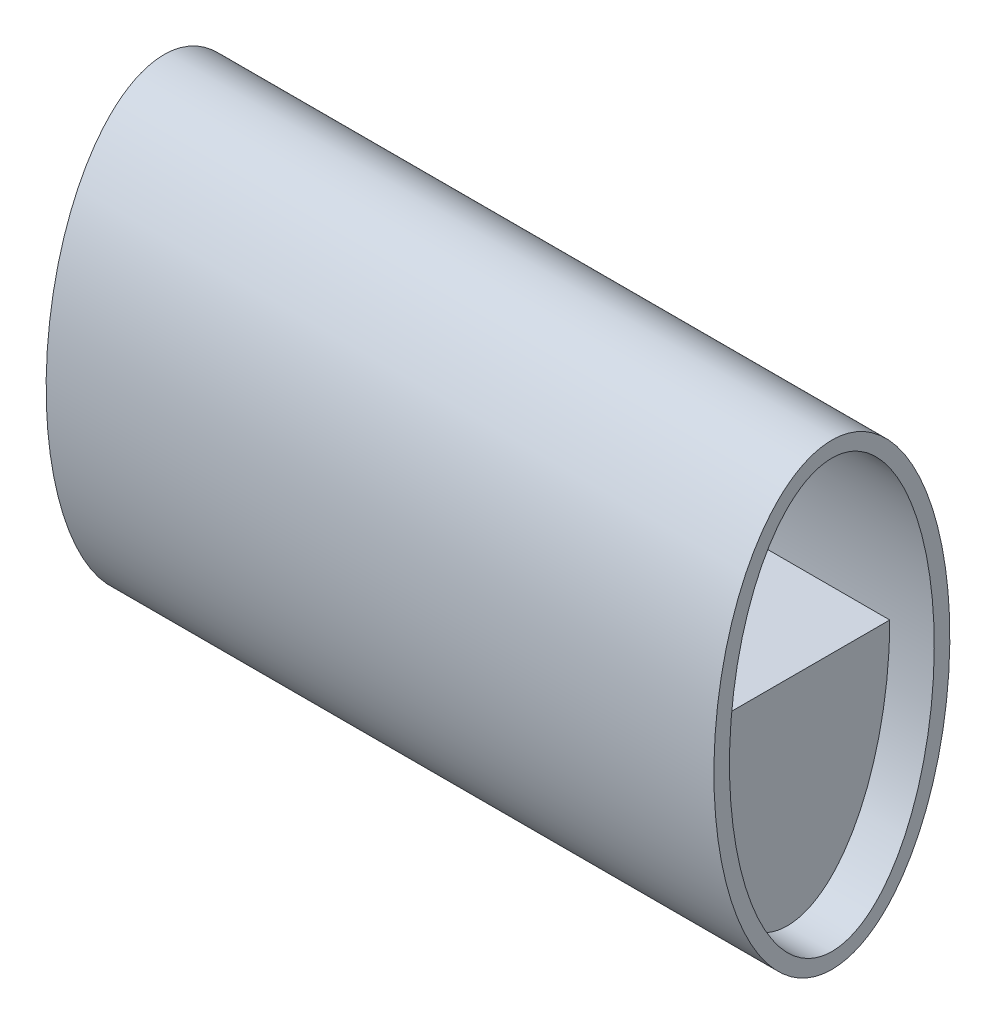
from build123d import *

# Parameters (mm, degrees)
SKETCH_1_RX              = 103
SKETCH_1_RY              = 53
SKETCH_1_RX_2            = 96
SKETCH_1_RY_2            = 46
EXTRUDE_1_DEPTH          = 300
SKETCH_2_RX              = 96
SKETCH_2_RY              = 46
EXTRUDE_2_DEPTH          = 30
EXTRUDE_2_DEPTH_BACK     = 30
SKETCH_3_RX              = 96
SKETCH_3_RY              = 46
CUT_EXTRUDE_1_DEPTH      = 27
CUT_EXTRUDE_1_DEPTH_BACK = 27
EXTRUDE_3_DEPTH          = 100
EXTRUDE_4_DEPTH          = 100
EXTRUDE_5_REACH          = 179


with BuildPart() as part:
    # Эскиз1 → Бобышка-Вытянуть1 (new body)
    with BuildSketch(Plane(origin=(0, 0, 0), x_dir=(0, 0, -1), z_dir=(1, 0, 0))):
        with Locations(Location((0, 0), (0, 0, -90))):
            Ellipse(SKETCH_1_RX, SKETCH_1_RY)
        with Locations(Location((0, 0), (0, 0, -90))):
            Ellipse(SKETCH_1_RX_2, SKETCH_1_RY_2, mode=Mode.SUBTRACT)
    extrude(amount=EXTRUDE_1_DEPTH)

    # Эскиз2 → Бобышка-Вытянуть2 (add, two sides)
    with BuildSketch(Plane.ZY.offset(-150)) as extrude_2_sk:
        with Locations(Location((0, 0), (0, 0, -90))):
            Ellipse(SKETCH_2_RX, SKETCH_2_RY)
    extrude(amount=EXTRUDE_2_DEPTH)
    extrude(extrude_2_sk.sketch, amount=-EXTRUDE_2_DEPTH_BACK)

    # Эскиз3 → Вырез-Вытянуть1 (cut, two sides)
    with BuildSketch(Plane.ZY.offset(-150)) as cut_extrude_1_sk:
        with Locations(Location((0, 0), (0, 0, 90))):
            Ellipse(SKETCH_3_RX, SKETCH_3_RY)
    extrude(amount=CUT_EXTRUDE_1_DEPTH, mode=Mode.SUBTRACT)
    extrude(cut_extrude_1_sk.sketch, amount=-CUT_EXTRUDE_1_DEPTH_BACK, mode=Mode.SUBTRACT)

    # Эскиз4 → Бобышка-Вытянуть3 (add)
    with BuildSketch(Plane.ZY.offset(-120)):
        with BuildLine():
            Line((-46, 0), (46, 0))
            add(Edge.make_bspline(
                [(-46, 0), (-46, -96), (0, -96), (46, -96), (46, 0)],
                knots=[4.71238898, 4.71238898, 4.71238898, 6.283185307, 6.283185307, 7.853981634, 7.853981634, 7.853981634], degree=2, weights=[1, 0.707106781, 1, 0.707106781, 1]))
        make_face()
    extrude(amount=EXTRUDE_3_DEPTH)

    # Эскиз5 → Бобышка-Вытянуть4 (add)
    with BuildSketch(Plane(origin=(180, 0, 0), x_dir=(0, 0, -1), z_dir=(1, 0, 0))):
        with BuildLine():
            Line((-46, 0), (46, 0))
            add(Edge.make_bspline(
                [(-46, 0), (-46, -96), (0, -96), (46, -96), (46, 0)],
                knots=[4.71238898, 4.71238898, 4.71238898, 6.283185307, 6.283185307, 7.853981634, 7.853981634, 7.853981634], degree=2, weights=[1, 0.707106781, 1, 0.707106781, 1]))
        make_face()
    extrude(amount=EXTRUDE_4_DEPTH)

    # Эскиз6 → Бобышка-Вытянуть5 (add, up to next)
    with BuildSketch(Plane(origin=(123, 0, 0), x_dir=(0, 0, -1), z_dir=(1, 0, 0)), mode=Mode.PRIVATE) as extrude_5_sk1:
        with BuildLine():
            Line((-46, 0), (46, 0))
            add(Edge.make_bspline(
                [(-46, 0), (-46, -96), (0, -96), (46, -96), (46, 0)],
                knots=[4.71238898, 4.71238898, 4.71238898, 6.283185307, 6.283185307, 7.853981634, 7.853981634, 7.853981634], degree=2, weights=[1, 0.707106781, 1, 0.707106781, 1]))
        make_face()
    extrude_5_tool1 = extrude(extrude_5_sk1.sketch, amount=EXTRUDE_5_REACH, mode=Mode.PRIVATE) - part.part
    add(extrude_5_tool1.solids().sort_by_distance((123, -40.735468, 0))[0])


solid = part.part
